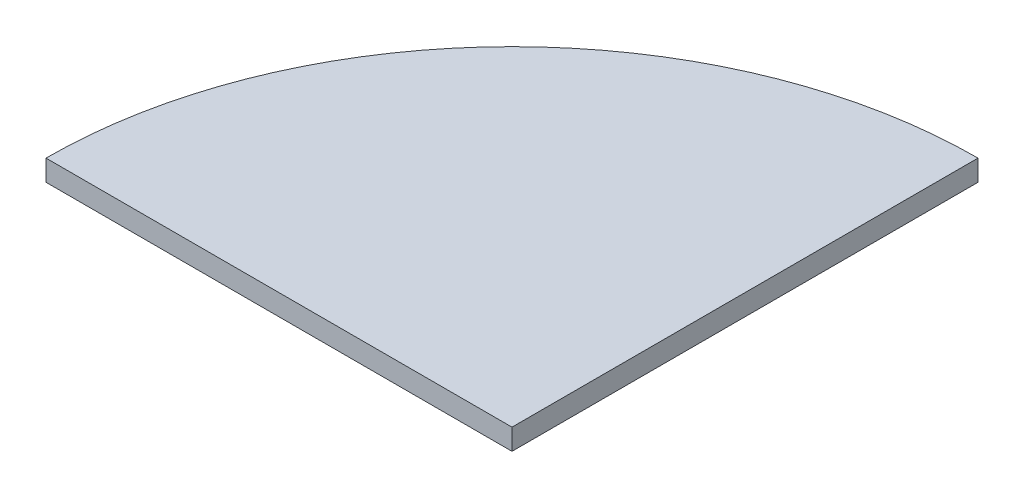
from build123d import *

# Parameters (mm, degrees)
EXTRUDE_1_DEPTH = 18


with BuildPart() as part:
    # Эскиз1 → Бобышка-Вытянуть1 (new body)
    with BuildSketch(Plane(origin=(0, 0, 0), x_dir=(1, 0, 0), z_dir=(0, 1, 0))):
        with BuildLine():
            Line((-400, 0), (0, 0))
            Line((0, 0), (0, 400))
            ThreePointArc((0, 400), (-282.842712475, 282.842712475), (-400, 0))
        make_face()
    extrude(amount=EXTRUDE_1_DEPTH)


solid = part.part
